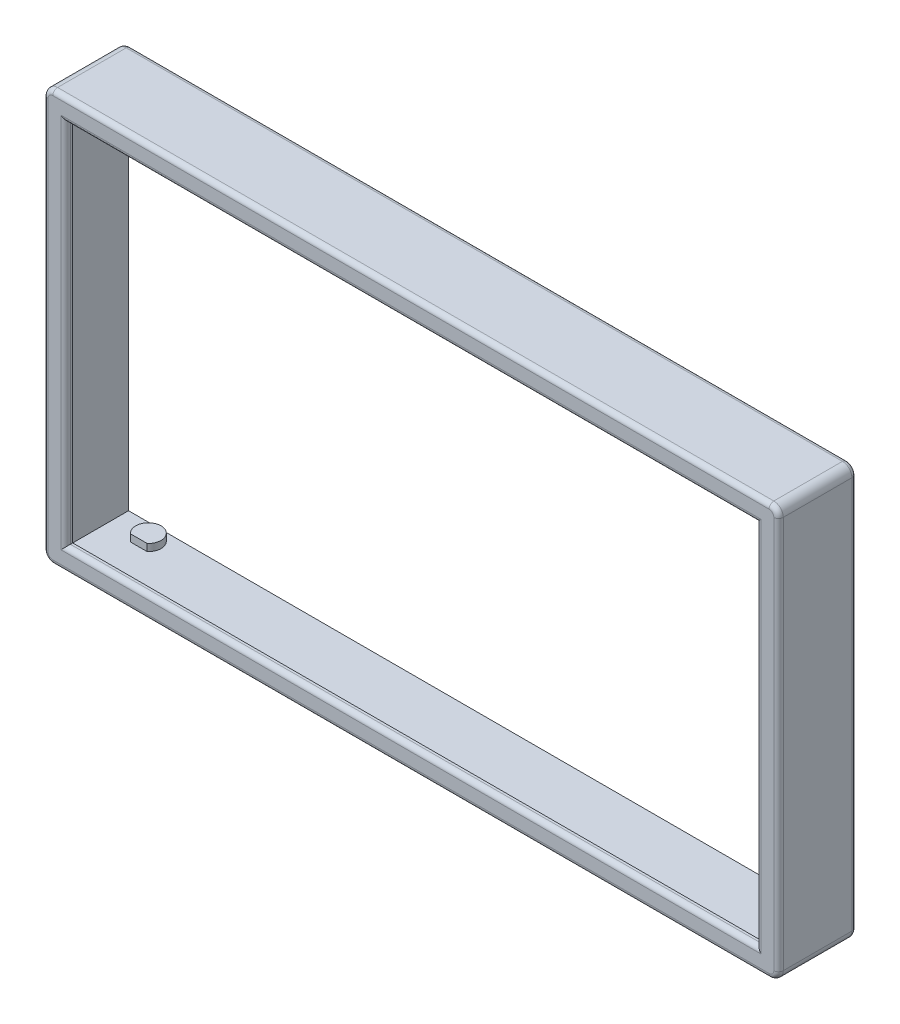
from build123d import *

# Parameters (mm, degrees)
SKETCH1_W           = 155.4
SKETCH1_H           = 86.98
SKETCH1_W_2         = 152.4
SKETCH1_H_2         = 83.98
SKETCH1_W_3         = 146
SKETCH1_H_3         = 77.58
BOSS_EXTRUDE1_DEPTH = 1.5
SKETCH1_3_W         = 155.4
SKETCH1_3_H         = 86.98
SKETCH1_3_W_2       = 152.4
SKETCH1_3_H_2       = 83.98
BOSS_EXTRUDE2_DEPTH = 15
FILLET1_R           = 2
FILLET2_R           = 1
BOSS_EXTRUDE3_DEPTH = 1.5
BOSS_EXTRUDE4_START = 83.98
SKETCH2_3_R         = 2.675
BOSS_EXTRUDE4_DEPTH = 0.85


with BuildPart() as part:
    # Sketch1 → Boss-Extrude1 (new body)
    with BuildSketch(Plane.XY.offset(120.134907759)):
        with Locations((-26.721041987, -25.88696544)):
            Rectangle(SKETCH1_W, SKETCH1_H)
        with Locations((-26.721041987, -25.88696544)):
            Rectangle(SKETCH1_W_2, SKETCH1_H_2, mode=Mode.SUBTRACT)
        with Locations((-26.721041987, -25.88696544)):
            Rectangle(SKETCH1_W_2, SKETCH1_H_2)
        with Locations((-26.721041987, -25.88696544)):
            Rectangle(SKETCH1_W_3, SKETCH1_H_3, mode=Mode.SUBTRACT)
    extrude(amount=BOSS_EXTRUDE1_DEPTH)

    # Sketch1_3 → Boss-Extrude2 (add)
    with BuildSketch(Plane.XY.offset(120.134907759)):
        with Locations((-26.721041987, -25.88696544)):
            Rectangle(SKETCH1_3_W, SKETCH1_3_H)
        with Locations((-26.721041987, -25.88696544)):
            Rectangle(SKETCH1_3_W_2, SKETCH1_3_H_2, mode=Mode.SUBTRACT)
    extrude(amount=-BOSS_EXTRUDE2_DEPTH)

    # Fillet1
    fillet1_edges = [part.edges().sort_by_distance(p)[0] for p in [
        (50.978958013, -69.37696544, 113.384907759),
        (-104.421041987, -69.37696544, 113.384907759),
        (-104.421041987, 17.60303456, 113.384907759),
        (50.978958013, 17.60303456, 113.384907759),
    ]]
    fillet(fillet1_edges, radius=FILLET1_R)

    # Fillet2
    fillet2_edges = [part.edges().sort_by_distance(p)[0] for p in [
        (-26.721041987, -64.67696544, 121.634907759),
        (-99.721041987, -25.88696544, 121.634907759),
        (-26.721041987, 12.90303456, 121.634907759),
        (46.278958013, -25.88696544, 121.634907759),
        (-26.721041987, -69.37696544, 105.134907759),
        (-26.721041987, -69.37696544, 121.634907759),
        (50.978958013, -25.88696544, 105.134907759),
        (-104.421041987, -25.88696544, 105.134907759),
        (-26.721041987, 17.60303456, 105.134907759),
        (50.393171575, -68.791179003, 105.134907759),
        (50.393171575, 17.017248122, 105.134907759),
        (-103.835255549, 17.017248122, 105.134907759),
        (-103.835255549, -68.791179003, 105.134907759),
        (-104.421041987, -25.88696544, 121.634907759),
        (50.978958013, -25.88696544, 121.634907759),
        (-26.721041987, 17.60303456, 121.634907759),
        (50.393171575, -68.791179003, 121.634907759),
        (50.393171575, 17.017248122, 121.634907759),
        (-103.835255549, 17.017248122, 121.634907759),
        (-103.835255549, -68.791179003, 121.634907759),
    ]]
    fillet(fillet2_edges, radius=FILLET2_R)

    # Sketch2 → Boss-Extrude3 (add)
    with BuildSketch(Plane(origin=(0, -67.87696544, 0), x_dir=(1, 0, 0), z_dir=(0, 1, 0))):
        with BuildLine():
            Line((-96.971041987, -110.65805506), (-93.471041987, -110.65805506))
            ThreePointArc((-93.471041987, -110.65805506), (-92.788258088, -109.747197065), (-92.546041987, -108.634907759))
            ThreePointArc((-92.546041987, -108.634907759), (-96.333331293, -106.20212386), (-96.971041987, -110.65805506))
        make_face()
        with BuildLine():
            Line((40.028958013, -110.65805506), (43.528958013, -110.65805506))
            ThreePointArc((43.528958013, -110.65805506), (44.211741912, -109.747197065), (44.453958013, -108.634907759))
            ThreePointArc((44.453958013, -108.634907759), (40.666668707, -106.20212386), (40.028958013, -110.65805506))
        make_face()
    extrude(amount=BOSS_EXTRUDE3_DEPTH)

    # Sketch2_3 → Boss-Extrude4 (add)
    with BuildSketch(Plane(origin=(0, -67.87696544, 0), x_dir=(1, 0, 0), z_dir=(0, 1, 0)).offset(BOSS_EXTRUDE4_START)):
        with BuildLine():
            Line((-96.971041987, -110.65805506), (-93.471041987, -110.65805506))
            ThreePointArc((-93.471041987, -110.65805506), (-92.788258088, -109.747197065), (-92.546041987, -108.634907759))
            ThreePointArc((-92.546041987, -108.634907759), (-96.333331293, -106.20212386), (-96.971041987, -110.65805506))
        make_face()
        with Locations((41.778958013, -108.634907759)):
            Circle(SKETCH2_3_R)
    extrude(amount=-BOSS_EXTRUDE4_DEPTH)


solid = part.part
